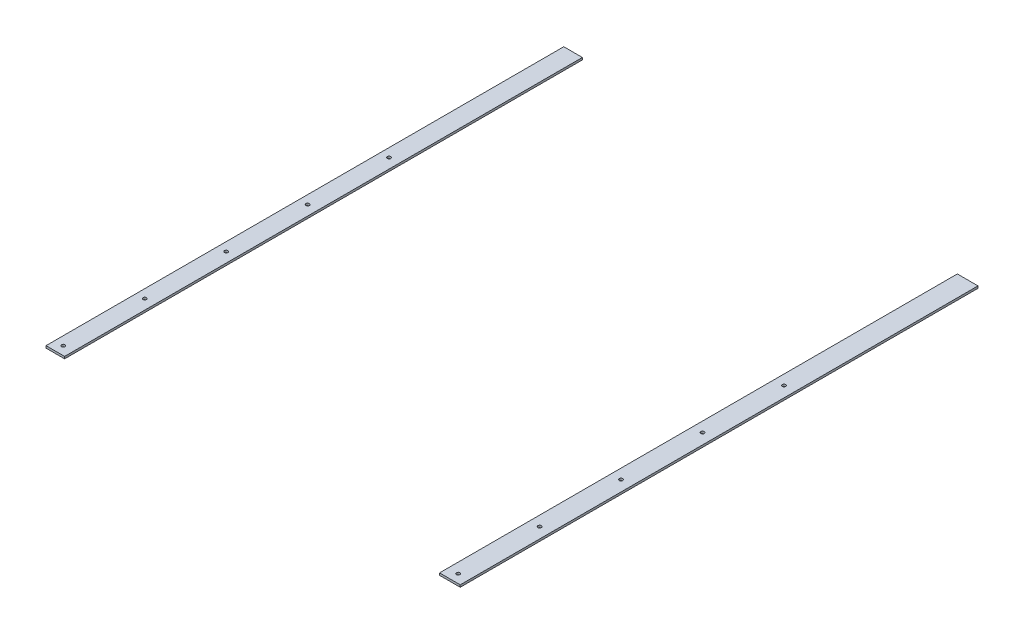
from build123d import *

# Parameters (mm, degrees)
SKETCH1_W           = 609.6
SKETCH1_H           = 762
SKETCH1_R           = 2.54
BOSS_EXTRUDE1_DEPTH = 3.175
CUT_EXTRUDE1_REACH  = 5.175
SKETCH2_W           = 551.81483812
SKETCH2_H           = 762


with BuildPart() as part:
    # Sketch1 → Boss-Extrude1 (new body)
    with BuildSketch(Plane(origin=(0, 0, 0), x_dir=(1, 0, 0), z_dir=(0, 1, 0))):
        with Locations((304.8, 381)):
            Rectangle(SKETCH1_W, SKETCH1_H)
        with Locations((12.7, 12.7)):
            Circle(SKETCH1_R, mode=Mode.SUBTRACT)
        with Locations((593.852, 12.7)):
            Circle(SKETCH1_R, mode=Mode.SUBTRACT)
        with Locations((593.852, 132.588)):
            Circle(SKETCH1_R, mode=Mode.SUBTRACT)
        with Locations((593.852, 252.476)):
            Circle(SKETCH1_R, mode=Mode.SUBTRACT)
        with Locations((593.852, 372.364)):
            Circle(SKETCH1_R, mode=Mode.SUBTRACT)
        with Locations((593.852, 492.252)):
            Circle(SKETCH1_R, mode=Mode.SUBTRACT)
        with Locations((12.7, 132.588)):
            Circle(SKETCH1_R, mode=Mode.SUBTRACT)
        with Locations((12.7, 252.476)):
            Circle(SKETCH1_R, mode=Mode.SUBTRACT)
        with Locations((12.7, 372.364)):
            Circle(SKETCH1_R, mode=Mode.SUBTRACT)
        with Locations((12.7, 492.252)):
            Circle(SKETCH1_R, mode=Mode.SUBTRACT)
    extrude(amount=BOSS_EXTRUDE1_DEPTH)

    # Sketch2 → Cut-Extrude1 (cut, up to next)
    with BuildSketch(Plane(origin=(0, 3.175, 0), x_dir=(1, 0, 0), z_dir=(0, 1, 0)), mode=Mode.PRIVATE) as cut_extrude1_sk1:
        with Locations((303.276, 381)):
            Rectangle(SKETCH2_W, SKETCH2_H)
    cut_extrude1_tool1 = extrude(cut_extrude1_sk1.sketch, amount=-CUT_EXTRUDE1_REACH, mode=Mode.PRIVATE) & part.part
    add(cut_extrude1_tool1.solids().sort_by_distance((303.276, 3.175, -381))[0], mode=Mode.SUBTRACT)


solid = part.part
